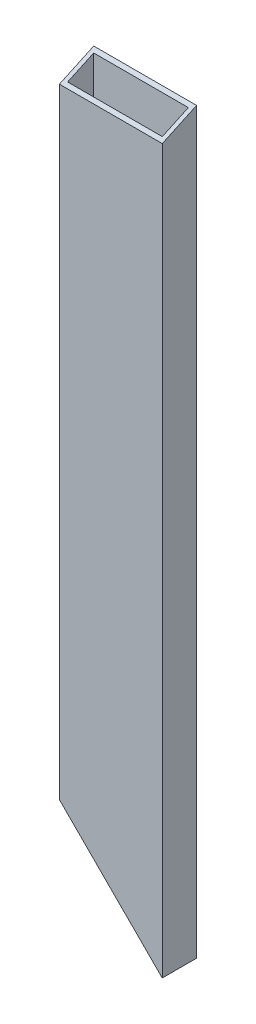
from build123d import *

# Parameters (mm, degrees)
SKETCH1_W               = 76.2
SKETCH1_H               = 25.4
SKETCH1_W_2             = 70.104
SKETCH1_H_2             = 19.304
BOSS_EXTRUDE1_DEPTH     = 503
SKETCH3_W               = 76.2
SKETCH3_H               = 25.4
SKETCH3_W_2             = 70.104
SKETCH3_H_2             = 19.304
BOSS_EXTRUDE2_DEPTH     = 38.1
CUT_EXTRUDE1_DEPTH      = 13.7
CUT_EXTRUDE1_DEPTH_BACK = 13.7
SKETCH4_W               = 76.2
SKETCH4_H               = 25.4
SKETCH4_W_2             = 70.104
SKETCH4_H_2             = 19.304
BOSS_EXTRUDE3_DEPTH     = 38.1
CUT_EXTRUDE4_DEPTH      = 77.2


with BuildPart() as part:
    # Sketch1 → Boss-Extrude1 (new body)
    with BuildSketch(Plane(origin=(0, 0, 0), x_dir=(1, 0, 0), z_dir=(0, 1, 0))):
        Rectangle(SKETCH1_W, SKETCH1_H)
        Rectangle(SKETCH1_W_2, SKETCH1_H_2, mode=Mode.SUBTRACT)
    extrude(amount=BOSS_EXTRUDE1_DEPTH)

    # Sketch3 → Boss-Extrude2 (add)
    with BuildSketch(Plane.XZ):
        Rectangle(SKETCH3_W, SKETCH3_H)
        Rectangle(SKETCH3_W_2, SKETCH3_H_2, mode=Mode.SUBTRACT)
    extrude(amount=BOSS_EXTRUDE2_DEPTH)

    # Sketch5 → Cut-Extrude1 (cut, two sides)
    with BuildSketch(Plane(origin=(0, 0.04766681, 0), x_dir=(0, -1, 0), z_dir=(0, 0, -1))) as cut_extrude1_sk:
        Polygon((-54.539816916, 54.485087066), (43.408433109, -43.279429016), (134.538834899, 48.02223888), (36.590584874, 145.786754963), align=None)
    extrude(amount=CUT_EXTRUDE1_DEPTH, mode=Mode.SUBTRACT)
    extrude(cut_extrude1_sk.sketch, amount=-CUT_EXTRUDE1_DEPTH_BACK, mode=Mode.SUBTRACT)

    # Sketch4 → Boss-Extrude3 (add)
    with BuildSketch(Plane(origin=(0, 503, 0), x_dir=(1, 0, 0), z_dir=(0, 1, 0))):
        Rectangle(SKETCH4_W, SKETCH4_H)
        Rectangle(SKETCH4_W_2, SKETCH4_H_2, mode=Mode.SUBTRACT)
    extrude(amount=BOSS_EXTRUDE3_DEPTH)

    # Sketch7 → Cut-Extrude4 (cut, through all)
    with BuildSketch(Plane(origin=(38.1, 0, 0), x_dir=(0, 0, -1), z_dir=(1, 0, 0))):
        Polygon((0, 503), (-33.872693161, 487.286257), (-33.967674724, 580.672666523), (15.906824851, 602.541381241), (53.592410045, 527.861836472), align=None)
    extrude(amount=-CUT_EXTRUDE4_DEPTH, mode=Mode.SUBTRACT)


solid = part.part
